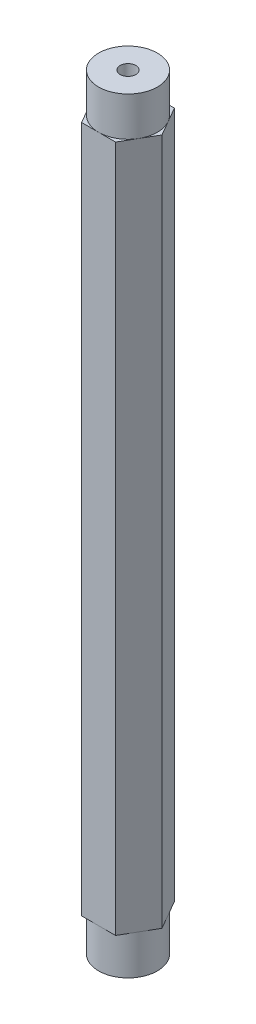
from build123d import *

# Parameters (mm, degrees)
SKETCH1_R           = 0.635
BOSS_EXTRUDE1_DEPTH = 27.813
SKETCH2_R           = 2.38125
SKETCH2_R_2         = 0.635
BOSS_EXTRUDE2_DEPTH = 3.175
SKETCH3_R           = 2.38125
SKETCH3_R_2         = 0.635
BOSS_EXTRUDE3_DEPTH = 3.175


with BuildPart() as part:
    # Sketch1 → Boss-Extrude1 (new body, symmetric)
    with BuildSketch(Plane(origin=(0, 0, 0), x_dir=(1, 0, 0), z_dir=(0, 1, 0))):
        Polygon((1.374815329, -2.38125), (2.749630657, 0), (1.374815329, 2.38125), (-1.374815329, 2.38125), (-2.749630657, 0), (-1.374815329, -2.38125), align=None)
        Circle(SKETCH1_R, mode=Mode.SUBTRACT)
    extrude(amount=BOSS_EXTRUDE1_DEPTH, both=True)

    # Sketch2 → Boss-Extrude2 (add)
    with BuildSketch(Plane(origin=(0, 27.813, 0), x_dir=(1, 0, 0), z_dir=(0, 1, 0))):
        Circle(SKETCH2_R)
        Circle(SKETCH2_R_2, mode=Mode.SUBTRACT)
    extrude(amount=BOSS_EXTRUDE2_DEPTH)

    # Sketch3 → Boss-Extrude3 (add)
    with BuildSketch(Plane.XZ.offset(27.813)):
        Circle(SKETCH3_R)
        Circle(SKETCH3_R_2, mode=Mode.SUBTRACT)
    extrude(amount=BOSS_EXTRUDE3_DEPTH)


solid = part.part
